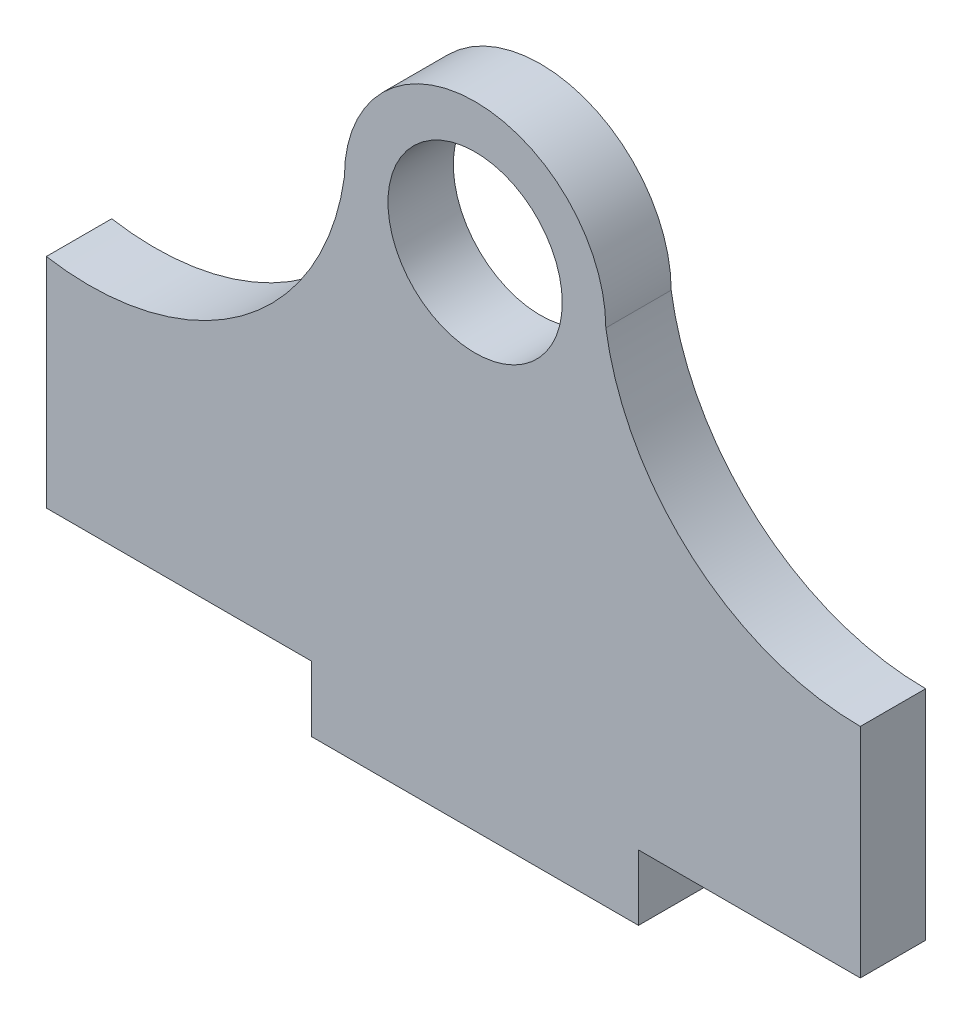
from build123d import *

# Parameters (mm, degrees)
SKETCH1_R           = 4
BOSS_EXTRUDE1_DEPTH = 3


with BuildPart() as part:
    # Sketch1 → Boss-Extrude1 (new body)
    with BuildSketch(Plane.XY):
        with BuildLine():
            Line((7.5, -20), (17.681043382, -20))
            Line((17.681043382, -20), (17.681043382, -10))
            ThreePointArc((17.681043382, -10), (9.992620207, -7.15854174), (6, 0))
            ThreePointArc((6, 0), (0, 6), (-6, 0))
            ThreePointArc((-6, 0), (-10.729319879, -7.888344359), (-19.681043382, -10))
            Line((-19.681043382, -10), (-19.681043382, -20))
            Line((-19.681043382, -20), (-7.5, -20))
            Line((-7.5, -20), (-7.5, -23))
            Line((-7.5, -23), (7.5, -23))
            Line((7.5, -23), (7.5, -20))
        make_face()
        Circle(SKETCH1_R, mode=Mode.SUBTRACT)
    extrude(amount=BOSS_EXTRUDE1_DEPTH)


solid = part.part
